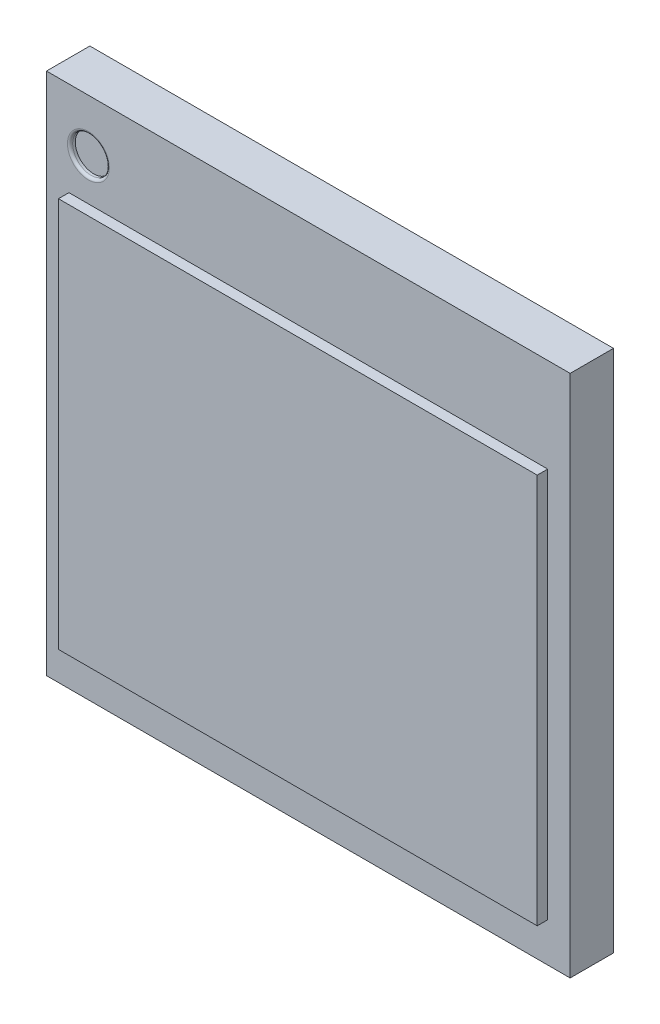
from build123d import *

# Parameters (mm, degrees)
BOSS_EXTRUDE1_START  = 0.21
SKETCH1_W            = 5
SKETCH1_H            = 5
BOSS_EXTRUDE1_DEPTH  = 0.414
LPATTERN1_COUNT      = 6
LPATTERN1_PITCH      = 0.75
LPATTERN1_COUNT_DIR2 = 6
LPATTERN1_PITCH_DIR2 = 0.8
SKETCH4_R            = 0.175
CUT_EXTRUDE1_DEPTH   = 0.05
FILLET1_R            = 0.025
SKETCH5_W            = 4.571597644
SKETCH5_H            = 3.727044465
BOSS_EXTRUDE2_DEPTH  = 0.1


with BuildPart() as part:
    # Sketch1 → Boss-Extrude1 (new body)
    with BuildSketch(Plane.XY.offset(BOSS_EXTRUDE1_START)):
        Rectangle(SKETCH1_W, SKETCH1_H)
    extrude(amount=BOSS_EXTRUDE1_DEPTH)

    # Sketch3 → Revolve1 (revolve)
    with BuildSketch(Plane(origin=(0, 1.9, 0), x_dir=(1, 0, 0), z_dir=(0, 1, 0))):
        with BuildLine():
            Line((-1.96, 0), (-1.96, -0.315))
            ThreePointArc((-1.96, -0.315), (-2.1175, -0.1575), (-1.96, 0))
        make_face()
    revolve1 = revolve(axis=Axis((-1.96, 1.9, 0.1575), (0, 0, -1)))

    # LPattern1: Revolve1 6 × 6, 8 skipped
    with Locations(*[(j * LPATTERN1_PITCH_DIR2, -i * LPATTERN1_PITCH, 0) for i in range(LPATTERN1_COUNT) for j in range(LPATTERN1_COUNT_DIR2) if (i, j) not in ((0, 0), (2, 1), (2, 2), (2, 3), (2, 4), (3, 1), (3, 2), (3, 3), (3, 4))]):
        add(revolve1)

    # Sketch4 → Cut-Extrude1 (cut)
    with BuildSketch(Plane.XY.offset(0.624)):
        with Locations((-2.1, 2)):
            Circle(SKETCH4_R)
    extrude(amount=-CUT_EXTRUDE1_DEPTH, mode=Mode.SUBTRACT)

    # Fillet1
    fillet1_edges = [part.edges().sort_by_distance(p)[0] for p in [
        (-2.275, 2, 0.624),
    ]]
    fillet(fillet1_edges, radius=FILLET1_R)

    # Sketch5 → Boss-Extrude2 (add)
    with BuildSketch(Plane.XY.offset(0.624)):
        with Locations((0, -0.262169795)):
            Rectangle(SKETCH5_W, SKETCH5_H)
    extrude(amount=BOSS_EXTRUDE2_DEPTH)


solid = part.part
